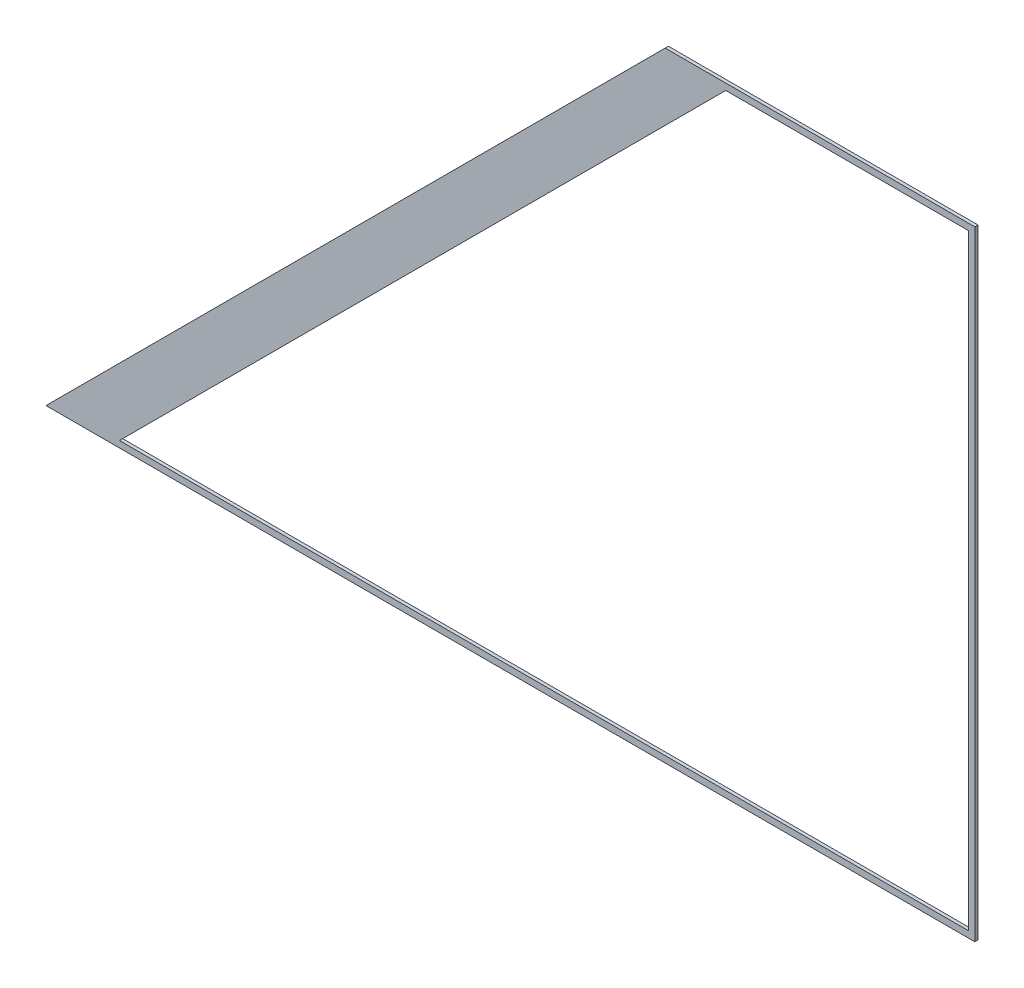
from build123d import *

# Parameters (mm, degrees)
BOSS_EXTRUDE1_DEPTH = 3.175
CUT_EXTRUDE1_DEPTH  = 4.175


with BuildPart() as part:
    # Sketch1 → Boss-Extrude1 (new body)
    with BuildSketch(Plane.XY):
        Polygon((0, 0), (914.4, 0), (914.4, 609.6), (609.6, 609.6), align=None)
    extrude(amount=BOSS_EXTRUDE1_DEPTH)

    # Sketch2 → Cut-Extrude1 (cut, through all)
    with BuildSketch(Plane.XY.offset(3.175)):
        Polygon((72.309153243, 6.35), (908.05, 6.35), (908.05, 603.25), (669.209153243, 603.25), align=None)
    extrude(amount=-CUT_EXTRUDE1_DEPTH, mode=Mode.SUBTRACT)


solid = part.part
